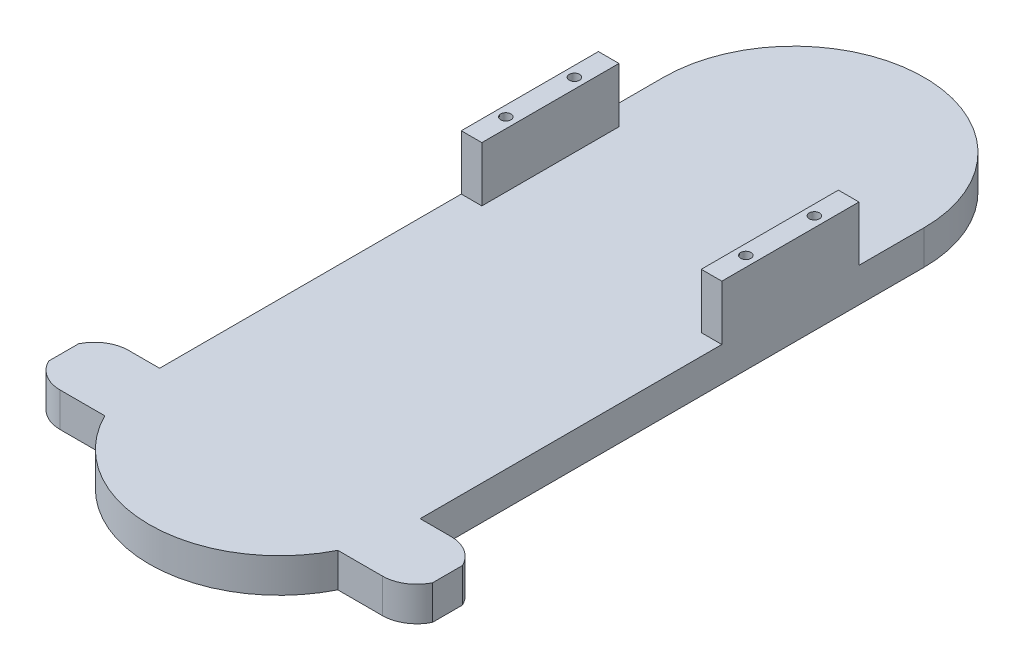
from build123d import *

# Parameters (mm, degrees)
EXTRUDE_1_DEPTH     = 10
SKETCH_4_W          = 6
SKETCH_4_H          = 40
EXTRUDE_3_DEPTH     = 16
SKETCH_7_R          = 1.5
CUT_EXTRUDE_3_DEPTH = 10
EXTRUDE_4_DEPTH     = 10


with BuildPart() as part:
    # 草图1 → 凸台-拉伸1 (new body)
    with BuildSketch(Plane(origin=(0, 0, 0), x_dir=(1, 0, 0), z_dir=(0, 1, 0))):
        with BuildLine():
            Line((-38, -75), (-38, 75))
            ThreePointArc((-38, 75), (0, 113), (38, 75))
            Line((38, 75), (38, -75))
            ThreePointArc((38, -75), (0, -113), (-38, -75))
        make_face()
    extrude(amount=EXTRUDE_1_DEPTH)

    # 草图4 → 凸台-拉伸3 (add)
    with BuildSketch(Plane(origin=(0, 10, 0), x_dir=(1, 0, 0), z_dir=(0, 1, 0))):
        with Locations((-35, 36)):
            Rectangle(SKETCH_4_W, SKETCH_4_H)
        with Locations((35, 36)):
            Rectangle(SKETCH_4_W, SKETCH_4_H)
    extrude(amount=EXTRUDE_3_DEPTH)

    # 草图7 → 切除-拉伸3 (cut)
    with BuildSketch(Plane(origin=(0, 26, 0), x_dir=(1, 0, 0), z_dir=(0, 1, 0))):
        with Locations((-35, 26)):
            Circle(SKETCH_7_R)
        with Locations((-35, 46)):
            Circle(SKETCH_7_R)
        with Locations((35, 26)):
            Circle(SKETCH_7_R)
        with Locations((35, 46)):
            Circle(SKETCH_7_R)
    extrude(amount=-CUT_EXTRUDE_3_DEPTH, mode=Mode.SUBTRACT)

    # 草图8 → 凸台-拉伸4 (add)
    with BuildSketch(Plane(origin=(0, 10, 0), x_dir=(1, 0, 0), z_dir=(0, 1, 0))):
        with BuildLine():
            Line((-47, -72), (47, -72))
            ThreePointArc((47, -72), (52.310885546, -73.526836794), (56, -77.641101056))
            Line((56, -77.641101056), (56, -86.358898944))
            ThreePointArc((56, -86.358898944), (52.310885546, -90.473163206), (47, -92))
            Line((47, -92), (-47, -92))
            ThreePointArc((-47, -92), (-52.310885546, -90.473163206), (-56, -86.358898944))
            Line((-56, -86.358898944), (-56, -77.641101056))
            ThreePointArc((-56, -77.641101056), (-52.310885546, -73.526836794), (-47, -72))
        make_face()
    extrude(amount=-EXTRUDE_4_DEPTH)


solid = part.part
